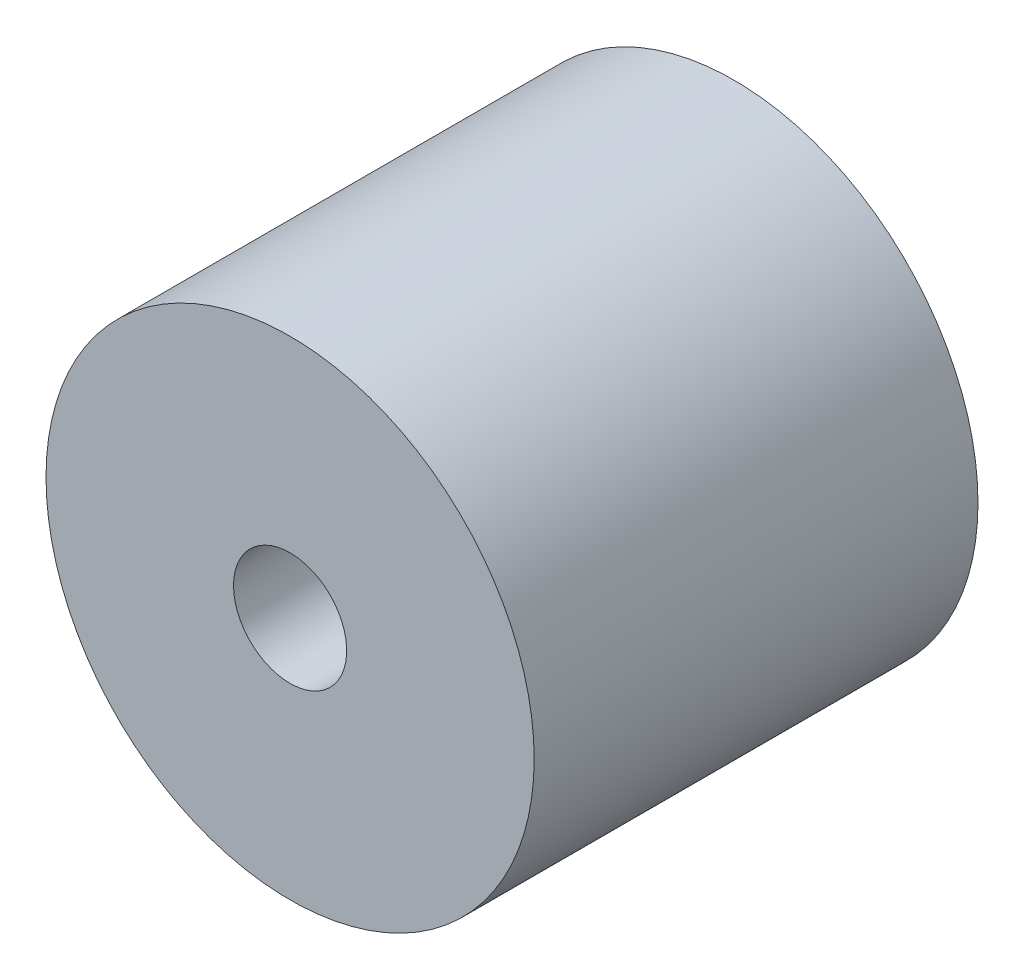
from build123d import *

# Parameters (mm, degrees)
SKETCH1_R           = 11
BOSS_EXTRUDE1_DEPTH = 20
SKETCH2_R           = 2.55
CUT_EXTRUDE1_DEPTH  = 20


with BuildPart() as part:
    # Sketch1 → Boss-Extrude1 (new body)
    with BuildSketch(Plane.XY):
        Circle(SKETCH1_R)
    extrude(amount=BOSS_EXTRUDE1_DEPTH)

    # Sketch2 → Cut-Extrude1 (cut)
    with BuildSketch(Plane(origin=(0, 0, 0), x_dir=(-1, 0, 0), z_dir=(0, 0, -1))):
        Circle(SKETCH2_R)
    extrude(amount=-CUT_EXTRUDE1_DEPTH, mode=Mode.SUBTRACT)


solid = part.part
